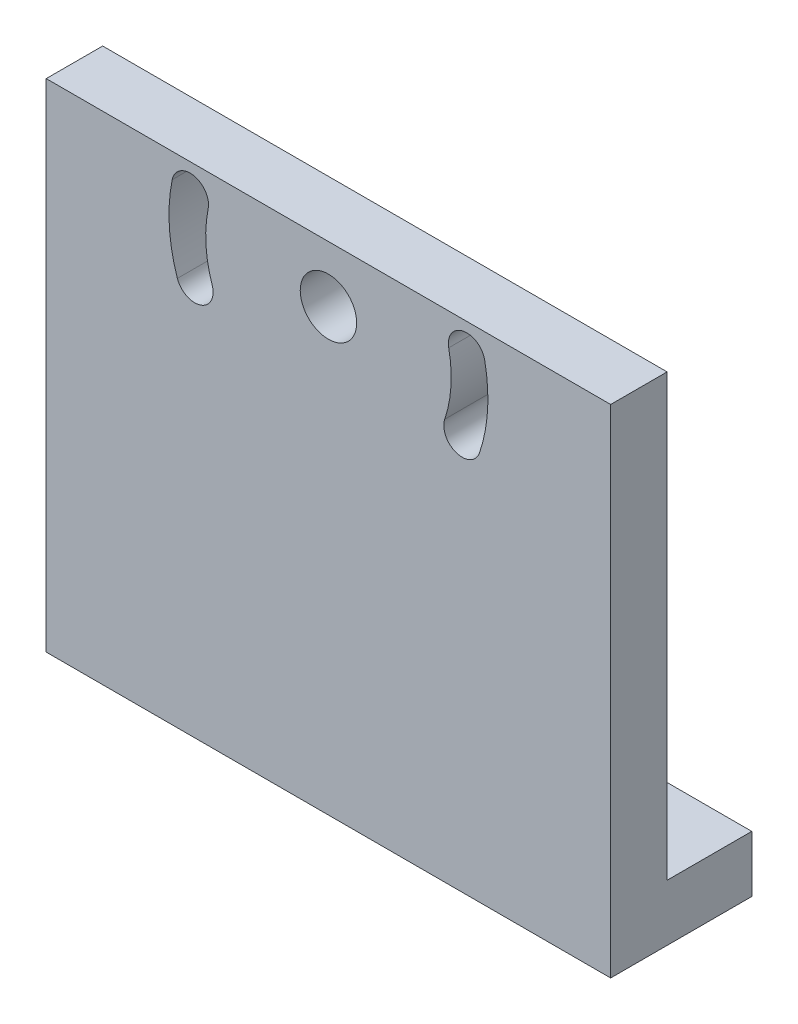
from build123d import *

# Parameters (mm, degrees)
EXTRUDE_1_DEPTH     = 10
SKETCH_2_W          = 169.882057187
SKETCH_2_H          = 25.097327733
CUT_EXTRUDE_1_DEPTH = 11
SKETCH_4_W          = 150
SKETCH_4_H          = 103
EXTRUDE_2_DEPTH     = 10
SKETCH_5_W          = 50
SKETCH_5_H          = 103
CUT_EXTRUDE_2_DEPTH = 11
SKETCH_7_W          = 130.949422717
SKETCH_7_H          = 60
CUT_EXTRUDE_3_DEPTH = 10
SKETCH_8_R          = 5
CUT_EXTRUDE_4_DEPTH = 11
CUT_EXTRUDE_5_DEPTH = 11
SKETCH_12_W         = 100
SKETCH_12_H         = 10
EXTRUDE_3_DEPTH     = 45
SKETCH_13_W         = 100
SKETCH_13_H         = 5
EXTRUDE_4_DEPTH     = 25
SKETCH_14_W         = 100
SKETCH_14_H         = 15
EXTRUDE_5_DEPTH     = 5
SKETCH_15_R         = 2.75
CUT_EXTRUDE_6_DEPTH = 11


with BuildPart() as part:
    # 草图1 → 凸台-拉伸1 (new body)
    with BuildSketch(Plane.XY):
        Polygon((150, 103.55), (0, 90.426700471), (0, 0), (150, 0), align=None)
    extrude(amount=EXTRUDE_1_DEPTH)

    # 草图2 → 切除-拉伸1 (cut, through all)
    with BuildSketch(Plane(origin=(0, 0, 0), x_dir=(-1, 0, 0), z_dir=(0, 0, -1))):
        with Locations((-84.941028594, 102.975364337)):
            Rectangle(SKETCH_2_W, SKETCH_2_H)
    extrude(amount=-CUT_EXTRUDE_1_DEPTH, mode=Mode.SUBTRACT)

    # 草图4 → 凸台-拉伸2 (add)
    with BuildSketch(Plane.XY.offset(10)):
        with Locations((75, 51.5)):
            Rectangle(SKETCH_4_W, SKETCH_4_H)
    extrude(amount=-EXTRUDE_2_DEPTH)

    # 草图5 → 切除-拉伸2 (cut, through all)
    with BuildSketch(Plane.XY.offset(10)):
        with Locations((125, 51.5)):
            Rectangle(SKETCH_5_W, SKETCH_5_H)
    extrude(amount=-CUT_EXTRUDE_2_DEPTH, mode=Mode.SUBTRACT)

    # 草图7 → 切除-拉伸3 (cut)
    with BuildSketch(Plane.XY.offset(10)):
        with Locations((65.474711359, 73)):
            Rectangle(SKETCH_7_W, SKETCH_7_H)
    extrude(amount=-CUT_EXTRUDE_3_DEPTH, mode=Mode.SUBTRACT)

    # 草图8 → 切除-拉伸4 (cut, through all)
    with BuildSketch(Plane(origin=(0, 0, 0), x_dir=(-1, 0, 0), z_dir=(0, 0, -1))):
        with Locations((-50, 33)):
            Circle(SKETCH_8_R)
    extrude(amount=-CUT_EXTRUDE_4_DEPTH, mode=Mode.SUBTRACT)

    # 草图11 → 切除-拉伸5 (cut, through all)
    with BuildSketch(Plane(origin=(0, 0, 0), x_dir=(-1, 0, 0), z_dir=(0, 0, -1))):
        with BuildLine():
            ThreePointArc((-76.764545578, 23.96), (-72.645438565, 21.920892987), (-70.606331551, 26.04))
            ThreePointArc((-70.606331551, 26.04), (-71.707959146, 31.648330774), (-71.310560762, 37.35))
            ThreePointArc((-71.310560762, 37.35), (-73.844897428, 41.184336666), (-77.679234093, 38.65))
            ThreePointArc((-77.679234093, 38.65), (-78.195395213, 31.24438365), (-76.764545578, 23.96))
        make_face()
    cut_extrude_5 = extrude(amount=-CUT_EXTRUDE_5_DEPTH, mode=Mode.SUBTRACT)

    # 镜向1: 切除-拉伸5 across plane
    add(cut_extrude_5.mirror(Plane.ZY.offset(-50)), mode=Mode.SUBTRACT)

    # 草图12 → 凸台-拉伸3 (add)
    with BuildSketch(Plane.XZ):
        with Locations((50, 5)):
            Rectangle(SKETCH_12_W, SKETCH_12_H)
    extrude(amount=EXTRUDE_3_DEPTH)

    # 草图13 → 凸台-拉伸4 (add)
    with BuildSketch(Plane.XY.offset(10)):
        with Locations((50, -42.5)):
            Rectangle(SKETCH_13_W, SKETCH_13_H)
    extrude(amount=-EXTRUDE_4_DEPTH)

    # 草图14 → 凸台-拉伸5 (add)
    with BuildSketch(Plane(origin=(0, -40, 0), x_dir=(1, 0, 0), z_dir=(0, 1, 0))):
        with Locations((50, 7.5)):
            Rectangle(SKETCH_14_W, SKETCH_14_H)
    extrude(amount=EXTRUDE_5_DEPTH)

    # 草图15 → 切除-拉伸6 (cut, through all)
    with BuildSketch(Plane(origin=(0, -35, 0), x_dir=(1, 0, 0), z_dir=(0, 1, 0))):
        with Locations((82.5, 6.885250494)):
            Circle(SKETCH_15_R)
        with Locations((17.5, 6.885250494)):
            Circle(SKETCH_15_R)
    extrude(amount=-CUT_EXTRUDE_6_DEPTH, mode=Mode.SUBTRACT)


solid = part.part
